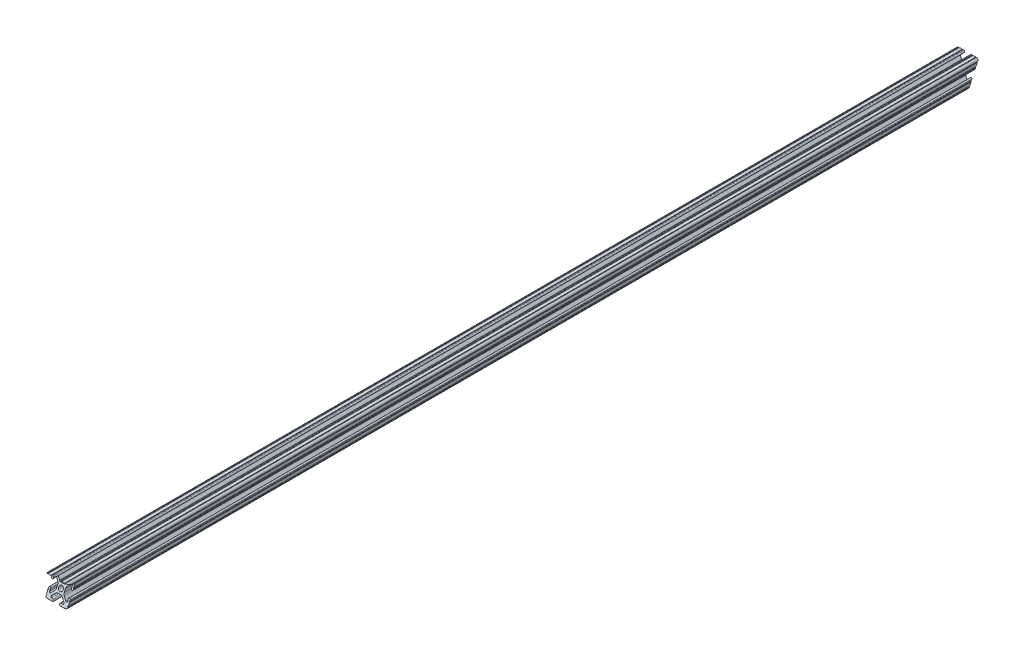
from build123d import *

# Parameters (mm, degrees)
SKETCH1_R               = 2.6035
BOSS_EXTRUDE1_DEPTH     = 539.0896
CUT_EXTRUDE2_DEPTH      = 13.7
CUT_EXTRUDE2_DEPTH_BACK = 13.7


with BuildPart() as part:
    # Sketch1 → Boss-Extrude1 (new body, symmetric)
    with BuildSketch(Plane(origin=(0, 0, -450.85), x_dir=(-1, 0, 0), z_dir=(0, 0, -1))):
        with BuildLine():
            Line((12.7, -9.5504), (12.7, -6.3330836))
            ThreePointArc((12.7, -6.3330836), (12.192, -5.8250836), (12.7, -5.3170836))
            Line((12.7, -5.3170836), (12.7, -4.3434))
            ThreePointArc((12.7, -4.3434), (11.5951, -3.2385), (10.4902, -4.3434))
            Line((10.4902, -4.3434), (10.4902, -6.474794456))
            ThreePointArc((10.4902, -6.474794456), (9.863006367, -7.413456061), (8.75577951, -7.193214945))
            Line((8.75577951, -7.193214945), (5.42573597, -3.863171405))
            ThreePointArc((5.42573597, -3.863171405), (4.737482484, -2.833127272), (4.4958, -1.618107374))
            Line((4.4958, -1.618107374), (4.4958, 1.618107374))
            ThreePointArc((4.4958, 1.618107374), (4.737482484, 2.833127272), (5.42573597, 3.863171405))
            Line((5.42573597, 3.863171405), (8.75577951, 7.193214945))
            ThreePointArc((8.75577951, 7.193214945), (9.863006367, 7.413456061), (10.4902, 6.474794456))
            Line((10.4902, 6.474794456), (10.4902, 4.343399971))
            ThreePointArc((10.4902, 4.343399971), (11.5951, 3.238499971), (12.7, 4.343399971))
            Line((12.7, 4.343399971), (12.7, 5.3170836))
            ThreePointArc((12.7, 5.3170836), (12.192, 5.8250836), (12.7, 6.3330836))
            Line((12.7, 6.3330836), (12.7, 9.5504))
            ThreePointArc((12.7, 9.5504), (12.192000006, 10.058323491), (12.699846982, 10.566399977))
            ThreePointArc((12.699846982, 10.566399977), (12.082522516, 12.082522516), (10.566399977, 12.699846982))
            ThreePointArc((10.566399977, 12.699846982), (10.058323491, 12.192000006), (9.5504, 12.7))
            Line((9.5504, 12.7), (6.3330836, 12.7))
            ThreePointArc((6.3330836, 12.7), (5.8250836, 12.192), (5.3170836, 12.7))
            Line((5.3170836, 12.7), (4.3434, 12.7))
            ThreePointArc((4.3434, 12.7), (3.2385, 11.5951), (4.3434, 10.4902))
            Line((4.3434, 10.4902), (6.474794456, 10.4902))
            ThreePointArc((6.474794456, 10.4902), (7.413456061, 9.863006367), (7.193214945, 8.75577951))
            Line((7.193214945, 8.75577951), (3.863171405, 5.42573597))
            ThreePointArc((3.863171405, 5.42573597), (2.833127272, 4.737482484), (1.618107374, 4.4958))
            Line((1.618107374, 4.4958), (-1.618107374, 4.4958))
            ThreePointArc((-1.618107374, 4.4958), (-2.833127272, 4.737482484), (-3.863171405, 5.42573597))
            Line((-3.863171405, 5.42573597), (-7.193214945, 8.75577951))
            ThreePointArc((-7.193214945, 8.75577951), (-7.413456061, 9.863006367), (-6.474794456, 10.4902))
            Line((-6.474794456, 10.4902), (-4.343399971, 10.4902))
            ThreePointArc((-4.343399971, 10.4902), (-3.238499971, 11.5951), (-4.343399971, 12.7))
            Line((-4.343399971, 12.7), (-5.3170836, 12.7))
            ThreePointArc((-5.3170836, 12.7), (-5.8250836, 12.192), (-6.3330836, 12.7))
            Line((-6.3330836, 12.7), (-9.5504, 12.7))
            ThreePointArc((-9.5504, 12.7), (-10.058323491, 12.192000006), (-10.566399977, 12.699846982))
            ThreePointArc((-10.566399977, 12.699846982), (-12.082522516, 12.082522516), (-12.699846982, 10.566399977))
            ThreePointArc((-12.699846982, 10.566399977), (-12.192000006, 10.058323491), (-12.7, 9.5504))
            Line((-12.7, 9.5504), (-12.7, 6.3330836))
            ThreePointArc((-12.7, 6.3330836), (-12.192, 5.8250836), (-12.7, 5.3170836))
            Line((-12.7, 5.3170836), (-12.7, 4.3434))
            ThreePointArc((-12.7, 4.3434), (-11.5951, 3.2385), (-10.4902, 4.3434))
            Line((-10.4902, 4.3434), (-10.4902, 6.474794456))
            ThreePointArc((-10.4902, 6.474794456), (-9.863006367, 7.413456061), (-8.75577951, 7.193214945))
            Line((-8.75577951, 7.193214945), (-5.42573597, 3.863171405))
            ThreePointArc((-5.42573597, 3.863171405), (-4.737482484, 2.833127272), (-4.4958, 1.618107374))
            Line((-4.4958, 1.618107374), (-4.4958, -1.618107374))
            ThreePointArc((-4.4958, -1.618107374), (-4.737482484, -2.833127272), (-5.42573597, -3.863171405))
            Line((-5.42573597, -3.863171405), (-8.75577951, -7.193214945))
            ThreePointArc((-8.75577951, -7.193214945), (-9.863006367, -7.413456061), (-10.4902, -6.474794456))
            Line((-10.4902, -6.474794456), (-10.4902, -4.343399971))
            ThreePointArc((-10.4902, -4.343399971), (-11.5951, -3.238499971), (-12.7, -4.343399971))
            Line((-12.7, -4.343399971), (-12.7, -5.3170836))
            ThreePointArc((-12.7, -5.3170836), (-12.192, -5.8250836), (-12.7, -6.3330836))
            Line((-12.7, -6.3330836), (-12.7, -9.5504))
            ThreePointArc((-12.7, -9.5504), (-12.192000006, -10.058323491), (-12.699846982, -10.566399977))
            ThreePointArc((-12.699846982, -10.566399977), (-12.082522516, -12.082522516), (-10.566399977, -12.699846982))
            ThreePointArc((-10.566399977, -12.699846982), (-10.058323491, -12.192000006), (-9.5504, -12.7))
            Line((-9.5504, -12.7), (-6.3330836, -12.7))
            ThreePointArc((-6.3330836, -12.7), (-5.8250836, -12.192), (-5.3170836, -12.7))
            Line((-5.3170836, -12.7), (-4.3434, -12.7))
            ThreePointArc((-4.3434, -12.7), (-3.2385, -11.5951), (-4.3434, -10.4902))
            Line((-4.3434, -10.4902), (-6.474794456, -10.4902))
            ThreePointArc((-6.474794456, -10.4902), (-7.413456061, -9.863006367), (-7.193214945, -8.75577951))
            Line((-7.193214945, -8.75577951), (-3.863171405, -5.42573597))
            ThreePointArc((-3.863171405, -5.42573597), (-2.833127272, -4.737482484), (-1.618107374, -4.4958))
            Line((-1.618107374, -4.4958), (1.618107374, -4.4958))
            ThreePointArc((1.618107374, -4.4958), (2.833127272, -4.737482484), (3.863171405, -5.42573597))
            Line((3.863171405, -5.42573597), (7.193214945, -8.75577951))
            ThreePointArc((7.193214945, -8.75577951), (7.413456061, -9.863006367), (6.474794456, -10.4902))
            Line((6.474794456, -10.4902), (4.343399971, -10.4902))
            ThreePointArc((4.343399971, -10.4902), (3.238499971, -11.5951), (4.343399971, -12.7))
            Line((4.343399971, -12.7), (5.3170836, -12.7))
            ThreePointArc((5.3170836, -12.7), (5.8250836, -12.192), (6.3330836, -12.7))
            Line((6.3330836, -12.7), (9.5504, -12.7))
            ThreePointArc((9.5504, -12.7), (10.058323491, -12.192000006), (10.566399977, -12.699846982))
            ThreePointArc((10.566399977, -12.699846982), (12.082522516, -12.082522516), (12.699846982, -10.566399977))
            ThreePointArc((12.699846982, -10.566399977), (12.192000006, -10.058323491), (12.7, -9.5504))
        make_face()
        Circle(SKETCH1_R, mode=Mode.SUBTRACT)
    extrude(amount=BOSS_EXTRUDE1_DEPTH, both=True)

    # Sketch2 → Cut-Extrude2 (cut, two sides)
    with BuildSketch(Plane(origin=(0, 0, 0), x_dir=(0, 0, -1), z_dir=(1, 0, 0))) as cut_extrude2_sk:
        Polygon((-79.030508577, 8.745212893), (-88.2396, 12.699846982), (-101.048292807, 21.699279404), (-97.311113584, -6.062623399), (-88.2396, -12.699846982), align=None)
        Polygon((990.442416852, 50.12885935), (974.65896, 12.699846982), (952.537969595, -34.847055216), (990.442416852, -34.847055216), align=None)
    extrude(amount=CUT_EXTRUDE2_DEPTH, mode=Mode.SUBTRACT)
    extrude(cut_extrude2_sk.sketch, amount=-CUT_EXTRUDE2_DEPTH_BACK, mode=Mode.SUBTRACT)


solid = part.part
